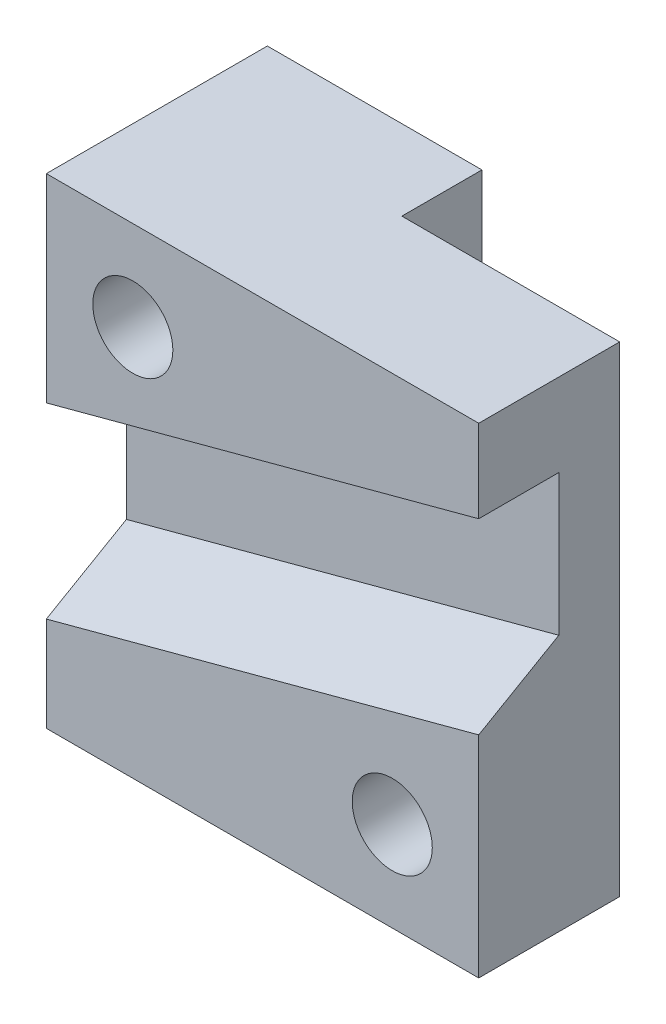
from build123d import *

# Parameters (mm, degrees)
BOSS_EXTRUDE1_DEPTH = 76.2
CUT_EXTRUDE1_DEPTH  = 72.034516633
SKETCH5_R           = 6.35
CUT_EXTRUDE2_DEPTH  = 36.052


with BuildPart() as part:
    # Sketch1 → Boss-Extrude1 (new body)
    with BuildSketch(Plane(origin=(0, 0, 0), x_dir=(1, 0, 0), z_dir=(0, 1, 0))):
        Polygon((0, 0), (0, -22.352), (-68.58, -22.352), (-68.58, 12.7), (-34.544, 12.7), (-34.544, 0), align=None)
    extrude(amount=BOSS_EXTRUDE1_DEPTH)

    # Sketch2 → Cut-Extrude1 (cut, through all, along a direction that is not the sketch's normal)
    with BuildSketch(Plane.ZY.offset(68.58)):
        Polygon((22.352, 44.704), (9.652, 44.704), (9.652, 22.352), (22.352, 15.019651581), align=None)
    extrude(amount=-CUT_EXTRUDE1_DEPTH, dir=(-0.965925826, -0.258819045, 0), mode=Mode.SUBTRACT)

    # Sketch5 → Cut-Extrude2 (cut, through all)
    with BuildSketch(Plane.XY.offset(22.352)):
        with Locations((-54.864, 61.976)):
            Circle(SKETCH5_R)
        with Locations((-13.716, 14.224)):
            Circle(SKETCH5_R)
    extrude(amount=-CUT_EXTRUDE2_DEPTH, mode=Mode.SUBTRACT)


solid = part.part
